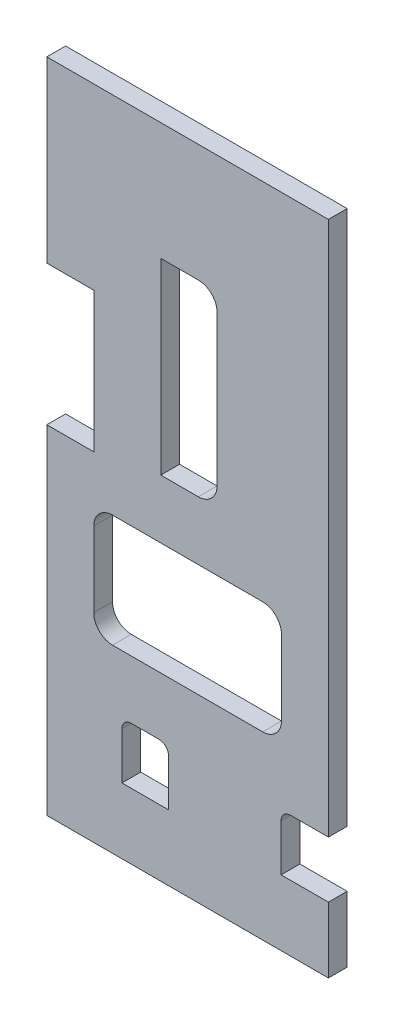
from build123d import *

# Parameters (mm, degrees)
SKETCH1_W           = 95.25
SKETCH1_H           = 222.25
BOSS_EXTRUDE1_DEPTH = 6.35
SKETCH2_W           = 17.693613984
SKETCH2_H           = 47.346544424
CUT_EXTRUDE1_DEPTH  = 15.875
CUT_EXTRUDE2_DEPTH  = 6.35
CUT_EXTRUDE3_DEPTH  = 6.35
CUT_EXTRUDE4_DEPTH  = 6.35


with BuildPart() as part:
    # Sketch1 → Boss-Extrude1 (new body)
    with BuildSketch(Plane.XY):
        with Locations((47.625, 111.125)):
            Rectangle(SKETCH1_W, SKETCH1_H)
    extrude(amount=BOSS_EXTRUDE1_DEPTH)

    # Sketch2 → Cut-Extrude1 (cut)
    with BuildSketch(Plane.ZY):
        with Locations((4.668229677, 138.138859748)):
            Rectangle(SKETCH2_W, SKETCH2_H)
    extrude(amount=-CUT_EXTRUDE1_DEPTH, mode=Mode.SUBTRACT)

    # Sketch3 → Cut-Extrude2 (cut)
    with BuildSketch(Plane(origin=(0, 0, 0), x_dir=(-1, 0, 0), z_dir=(0, 0, -1))):
        with BuildLine():
            Line((-51.25, 182.483066433), (-38.55, 182.483066433))
            Line((-38.55, 182.483066433), (-38.55, 118.983066433))
            Line((-38.55, 118.983066433), (-51.25, 118.983066433))
            ThreePointArc((-51.25, 118.983066433), (-55.740128061, 120.842938372), (-57.6, 125.333066433))
            Line((-57.6, 125.333066433), (-57.6, 176.133066433))
            ThreePointArc((-57.6, 176.133066433), (-55.740128061, 180.623194493), (-51.25, 182.483066433))
        make_face()
    extrude(amount=-CUT_EXTRUDE2_DEPTH, mode=Mode.SUBTRACT)

    # Sketch4 → Cut-Extrude3 (cut)
    with BuildSketch(Plane(origin=(0, 0, 0), x_dir=(-1, 0, 0), z_dir=(0, 0, -1))):
        with BuildLine():
            Line((-73.025, 99.100693086), (-22.225, 99.100693086))
            ThreePointArc((-22.225, 99.100693086), (-17.734871939, 97.240821147), (-15.875, 92.750693086))
            Line((-15.875, 92.750693086), (-15.875, 67.350693086))
            ThreePointArc((-15.875, 67.350693086), (-17.734871939, 62.860565025), (-22.225, 61.000693086))
            Line((-22.225, 61.000693086), (-73.025, 61.000693086))
            ThreePointArc((-73.025, 61.000693086), (-77.515128061, 62.860565025), (-79.375, 67.350693086))
            Line((-79.375, 67.350693086), (-79.375, 92.750693086))
            ThreePointArc((-79.375, 92.750693086), (-77.515128061, 97.240821147), (-73.025, 99.100693086))
        make_face()
    extrude(amount=-CUT_EXTRUDE3_DEPTH, mode=Mode.SUBTRACT)

    # Sketch5 → Cut-Extrude4 (cut)
    with BuildSketch(Plane(origin=(0, 0, 0), x_dir=(-1, 0, 0), z_dir=(0, 0, -1))):
        with BuildLine():
            Line((-95.25, 22.225), (-79.248, 22.225))
            Line((-79.248, 22.225), (-79.248, 38.1))
            ThreePointArc((-79.248, 38.1), (-80.17793597, 40.34506403), (-82.423, 41.275))
            Line((-82.423, 41.275), (-95.25, 41.275))
            Line((-95.25, 41.275), (-95.25, 22.225))
        make_face()
        with BuildLine():
            Line((-25.4, 22.225), (-25.4, 38.1))
            ThreePointArc((-25.4, 38.1), (-26.32993597, 40.34506403), (-28.575, 41.275))
            Line((-28.575, 41.275), (-37.973, 41.275))
            ThreePointArc((-37.973, 41.275), (-40.21806403, 40.34506403), (-41.148, 38.1))
            Line((-41.148, 38.1), (-41.148, 22.225))
            Line((-41.148, 22.225), (-25.4, 22.225))
        make_face()
    extrude(amount=-CUT_EXTRUDE4_DEPTH, mode=Mode.SUBTRACT)


solid = part.part
